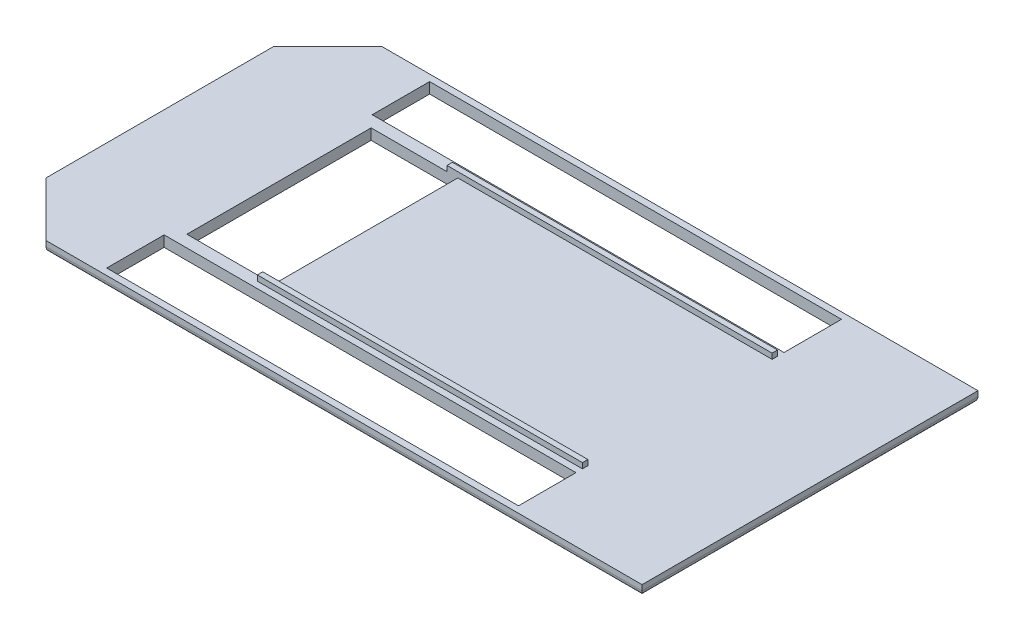
from build123d import *

# Parameters (mm, degrees)
BOSS_EXTRUDE2_DEPTH = 10
SKETCH2_W           = 300
SKETCH2_H           = 5
BOSS_EXTRUDE3_DEPTH = 5
FILLET1_R           = 5
SKETCH3_W           = 380
SKETCH3_H           = 53
SKETCH3_W_2         = 80
SKETCH3_H_2         = 170
CUT_EXTRUDE1_DEPTH  = 10


with BuildPart() as part:
    # Sketch1 → Boss-Extrude2 (new body)
    with BuildSketch(Plane(origin=(0, 0, 0), x_dir=(1, 0, 0), z_dir=(0, 1, 0))):
        Polygon((-300, 105), (-250, 155), (300, 155), (300, -155), (-250, -155), (-300, -105), align=None)
    extrude(amount=BOSS_EXTRUDE2_DEPTH)

    # Sketch2 → Boss-Extrude3 (add)
    with BuildSketch(Plane(origin=(0, 10, 0), x_dir=(1, 0, 0), z_dir=(0, 1, 0))):
        with Locations((30, -87.5)):
            Rectangle(SKETCH2_W, SKETCH2_H)
        with Locations((30, 87.5)):
            Rectangle(SKETCH2_W, SKETCH2_H)
    extrude(amount=BOSS_EXTRUDE3_DEPTH)

    # Fillet1
    fillet1_edges = [part.edges().sort_by_distance(p)[0] for p in [
        (25, 0, 155),
        (-275, 0, 130),
        (-300, 0, 0),
        (-275, 0, -130),
        (25, 0, -155),
        (300, 0, 0),
    ]]
    fillet(fillet1_edges, radius=FILLET1_R)

    # Sketch3 → Cut-Extrude1 (cut)
    with BuildSketch(Plane(origin=(0, 10, 0), x_dir=(1, 0, 0), z_dir=(0, 1, 0))):
        with Locations((-10, 122.5)):
            Rectangle(SKETCH3_W, SKETCH3_H)
        with Locations((-10, -122.5)):
            Rectangle(SKETCH3_W, SKETCH3_H)
        with Locations((-150, 0)):
            Rectangle(SKETCH3_W_2, SKETCH3_H_2)
    extrude(amount=-CUT_EXTRUDE1_DEPTH, mode=Mode.SUBTRACT)


solid = part.part
